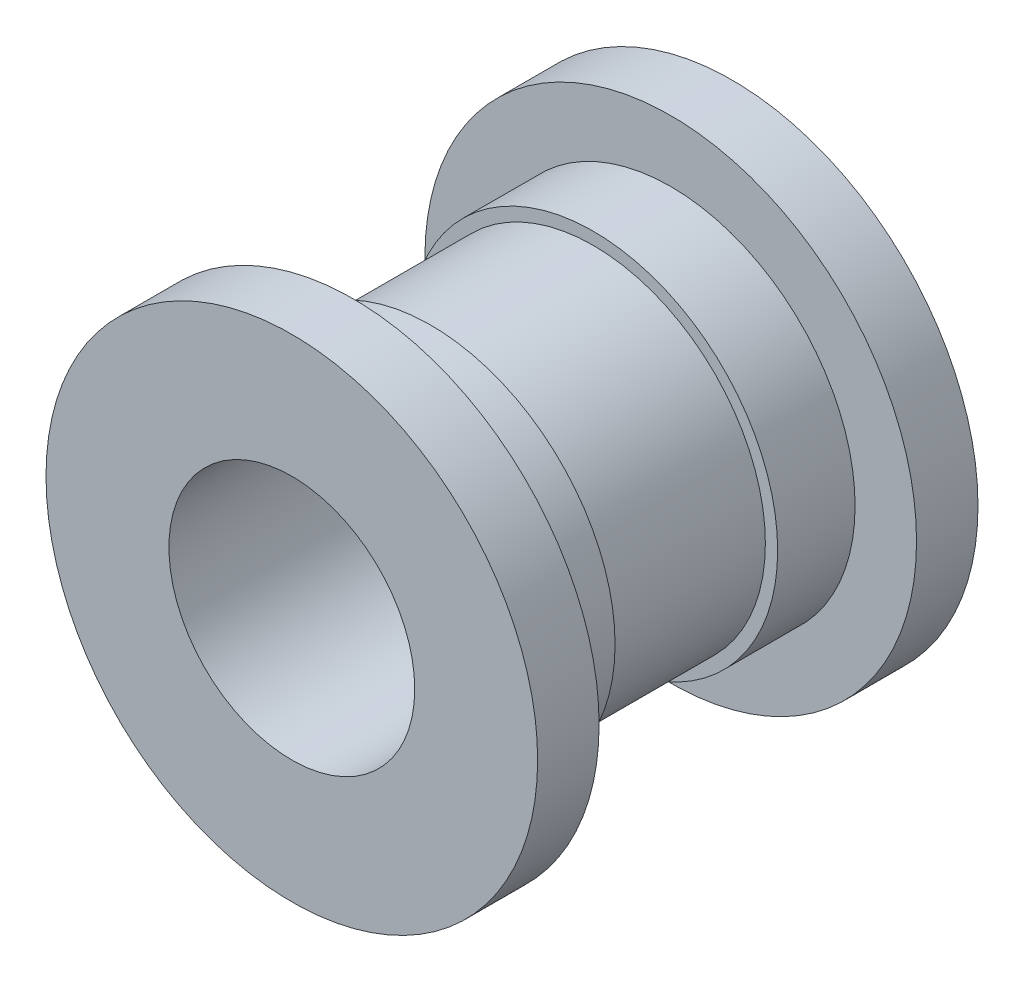
from build123d import *

# Parameters (mm, degrees)
SKETCH1_R           = 4.445
BOSS_EXTRUDE1_DEPTH = 2.1
SKETCH2_R           = 4.7625
BOSS_EXTRUDE2_DEPTH = 2
SKETCH4_R           = 6.35
BOSS_EXTRUDE4_DEPTH = 1.5875
SKETCH5_R           = 3.175
CUT_EXTRUDE1_DEPTH  = 12.375


with BuildPart() as part:
    # Sketch1 → Boss-Extrude1 (new body)
    with BuildSketch(Plane.XY):
        Circle(SKETCH1_R)
    boss_extrude1 = extrude(amount=BOSS_EXTRUDE1_DEPTH)

    # Sketch2 → Boss-Extrude2 (add)
    with BuildSketch(Plane.XY.offset(2.1)):
        Circle(SKETCH2_R)
    boss_extrude2 = extrude(amount=BOSS_EXTRUDE2_DEPTH)

    # Sketch4 → Boss-Extrude4 (add)
    with BuildSketch(Plane.XY.offset(4.1)):
        Circle(SKETCH4_R)
    boss_extrude4 = extrude(amount=BOSS_EXTRUDE4_DEPTH)

    # Mirror1: Boss-Extrude1, Boss-Extrude2, Boss-Extrude4 across plane
    add(boss_extrude1.mirror(Plane.XY))
    add(boss_extrude2.mirror(Plane.XY))
    add(boss_extrude4.mirror(Plane.XY))

    # Sketch5 → Cut-Extrude1 (cut, through all)
    with BuildSketch(Plane.XY.offset(5.6875)):
        Circle(SKETCH5_R)
    extrude(amount=-CUT_EXTRUDE1_DEPTH, mode=Mode.SUBTRACT)


solid = part.part
